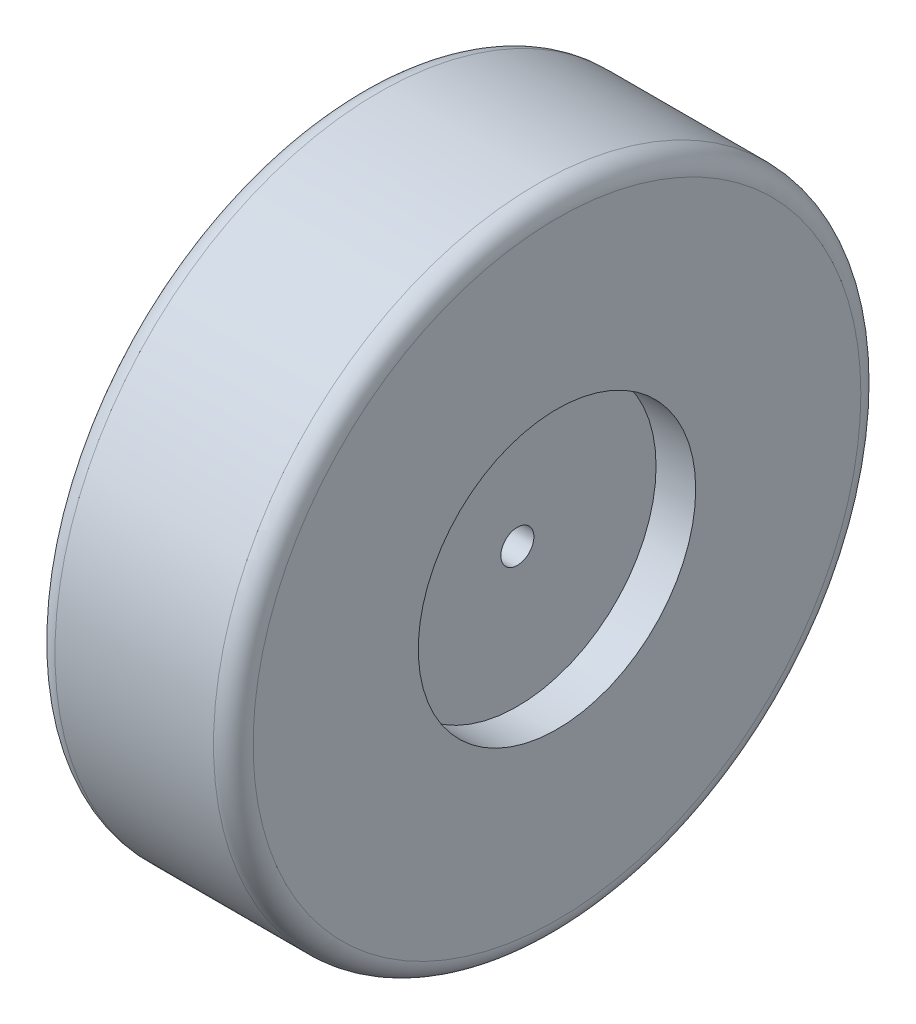
from build123d import *

# Parameters (mm, degrees)
SKETCH_1_R          = 49
EXTRUDE_1_DEPTH     = 30
FILLET_1_R          = 3
SKETCH_2_R          = 21
CUT_EXTRUDE_1_DEPTH = 6
SKETCH_3_R          = 2.5
CUT_EXTRUDE_2_DEPTH = 6


with BuildPart() as part:
    # 草图1 → 凸台-拉伸1 (new body)
    with BuildSketch(Plane(origin=(0, 0, 0), x_dir=(0, 0, -1), z_dir=(1, 0, 0))):
        Circle(SKETCH_1_R)
    extrude(amount=EXTRUDE_1_DEPTH)

    # 圆角1
    fillet_1_edges = [part.edges().sort_by_distance(p)[0] for p in [
        (0, 0, 49),
        (30, 0, 49),
    ]]
    fillet(fillet_1_edges, radius=FILLET_1_R)

    # 草图2 → 切除-拉伸1 (cut)
    with BuildSketch(Plane(origin=(30, 0, 0), x_dir=(0, 0, -1), z_dir=(1, 0, 0))):
        Circle(SKETCH_2_R)
    extrude(amount=-CUT_EXTRUDE_1_DEPTH, mode=Mode.SUBTRACT)

    # 草图3 → 切除-拉伸2 (cut)
    with BuildSketch(Plane(origin=(24, 0, 0), x_dir=(0, 0, -1), z_dir=(1, 0, 0))):
        Circle(SKETCH_3_R)
    extrude(amount=-CUT_EXTRUDE_2_DEPTH, mode=Mode.SUBTRACT)


solid = part.part
